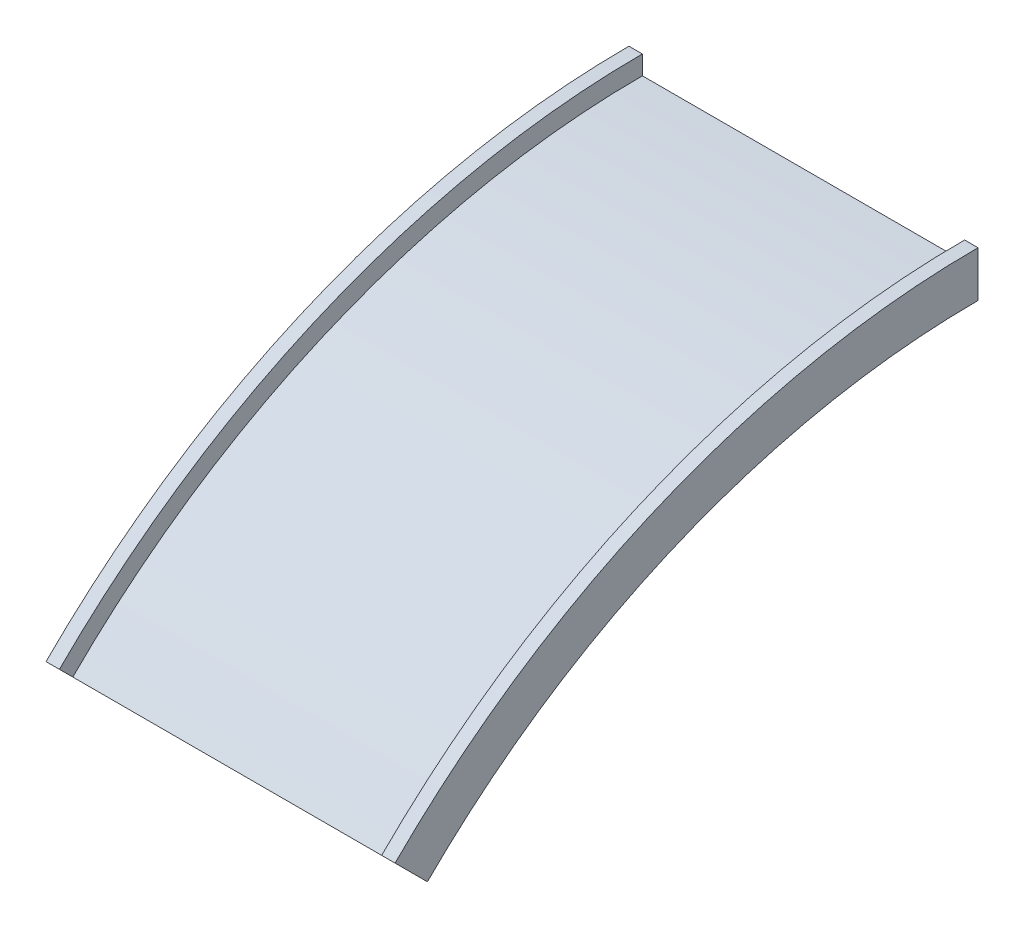
from build123d import *

# Parameters (mm, degrees)
REVOLVE2_ANGLE = 45


with BuildPart() as part:
    # Sketch1 → Revolve2 (revolve)
    with BuildSketch(Plane.XY):
        Polygon((0, 0), (25, 0), (25, -35.236081748), (625, -35.236081748), (625, 0), (650, 0), (650, -85.236081748), (0, -85.236081748), align=None)
    revolve(axis=Axis((0, -1535.236081748, 0), (1, 0, 0)), revolution_arc=REVOLVE2_ANGLE)


solid = part.part
